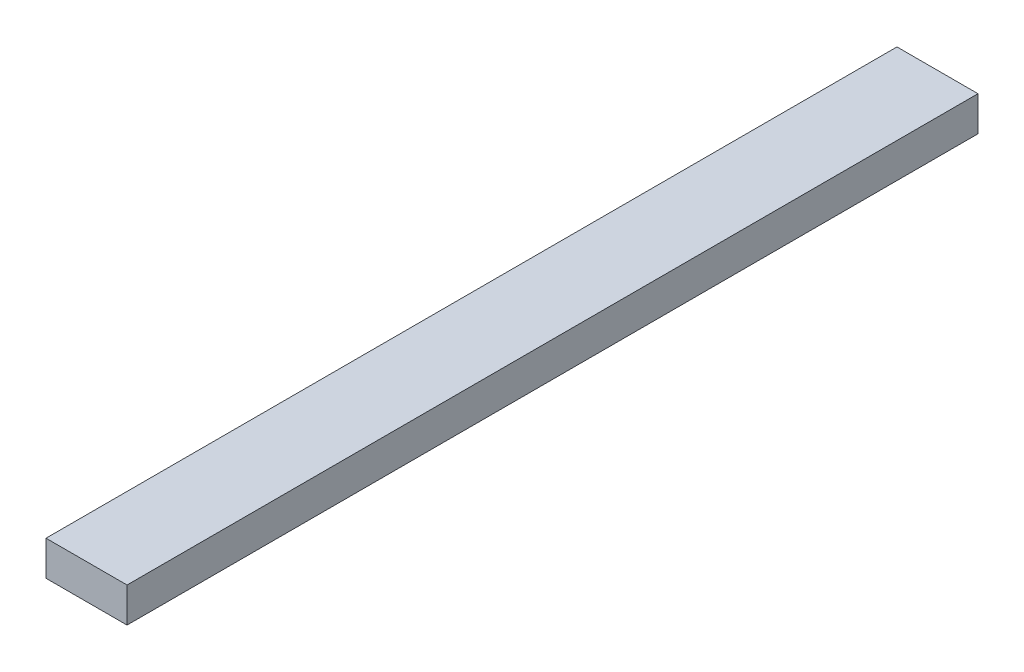
from build123d import *

# Parameters (mm, degrees)
SKETCH1_W           = 88.9
SKETCH1_H           = 38.1
BOSS_EXTRUDE1_DEPTH = 933.45


with BuildPart() as part:
    # Sketch1 → Boss-Extrude1 (new body)
    with BuildSketch(Plane.XY):
        with Locations((-14.400787144, 27.978087061)):
            Rectangle(SKETCH1_W, SKETCH1_H)
    extrude(amount=BOSS_EXTRUDE1_DEPTH)


solid = part.part
